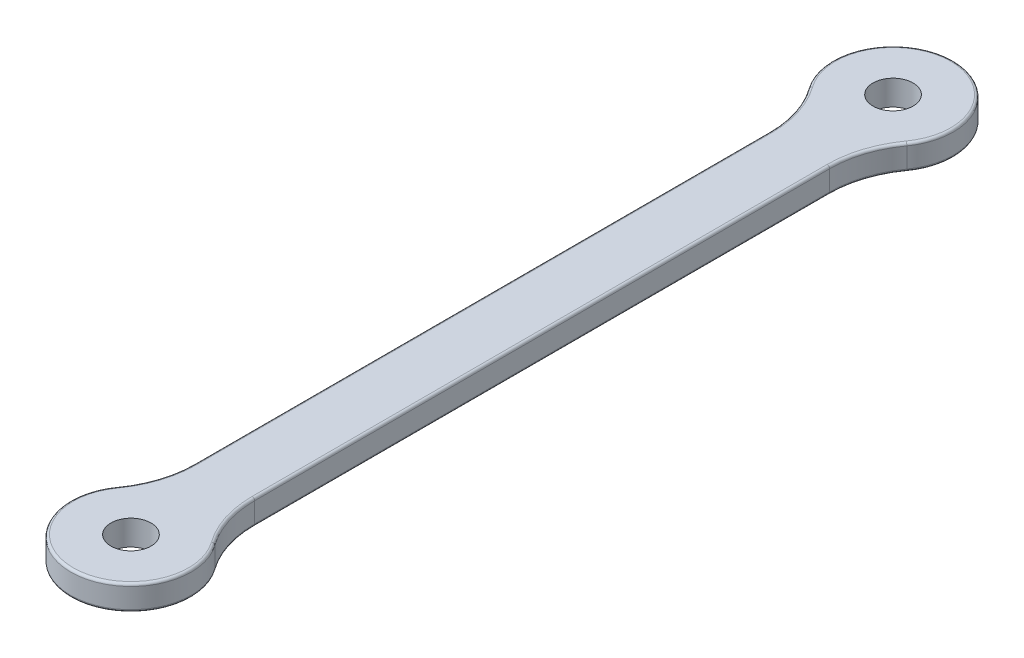
from build123d import *

# Parameters (mm, degrees)
SKETCH1_R           = 2
BOSS_EXTRUDE1_DEPTH = 2.5
FILLET1_R           = 10
FILLET2_R           = 0.25


with BuildPart() as part:
    # Sketch1 → Boss-Extrude1 (new body)
    with BuildSketch(Plane(origin=(0, 0, 0), x_dir=(1, 0, 0), z_dir=(0, 1, 0))):
        with BuildLine():
            ThreePointArc((-3, -32.803847577), (0, -44), (3, -32.803847577))
            Line((3, -32.803847577), (3, 32.803847577))
            ThreePointArc((3, 32.803847577), (0, 44), (-3, 32.803847577))
            Line((-3, 32.803847577), (-3, -32.803847577))
        make_face()
        with Locations((0, -38)):
            Circle(SKETCH1_R, mode=Mode.SUBTRACT)
        with Locations((0, 38)):
            Circle(SKETCH1_R, mode=Mode.SUBTRACT)
    extrude(amount=BOSS_EXTRUDE1_DEPTH)

    # Fillet1
    fillet1_edges = [part.edges().sort_by_distance(p)[0] for p in [
        (-3, 1.25, 32.803847577),
        (-3, 1.25, -32.803847577),
        (3, 1.25, -32.803847577),
        (3, 1.25, 32.803847577),
    ]]
    fillet(fillet1_edges, radius=FILLET1_R)

    # Fillet2
    fillet2_edges = [part.edges().sort_by_distance(p)[0] for p in [
        (0, 0, 44),
        (0, 2.5, 44),
        (-3, 0, 0),
        (-3, 2.5, 0),
        (0, 0, -44),
        (0, 2.5, -44),
        (3, 0, 0),
        (3, 2.5, 0),
        (-3.480283618, 0, 31.734483125),
        (-3.480283618, 2.5, 31.734483125),
        (-3.480283618, 0, -31.734483125),
        (-3.480283618, 2.5, -31.734483125),
        (3.480283618, 0, -31.734483125),
        (3.480283618, 2.5, -31.734483125),
        (3.480283618, 0, 31.734483125),
        (3.480283618, 2.5, 31.734483125),
    ]]
    fillet(fillet2_edges, radius=FILLET2_R)


solid = part.part
